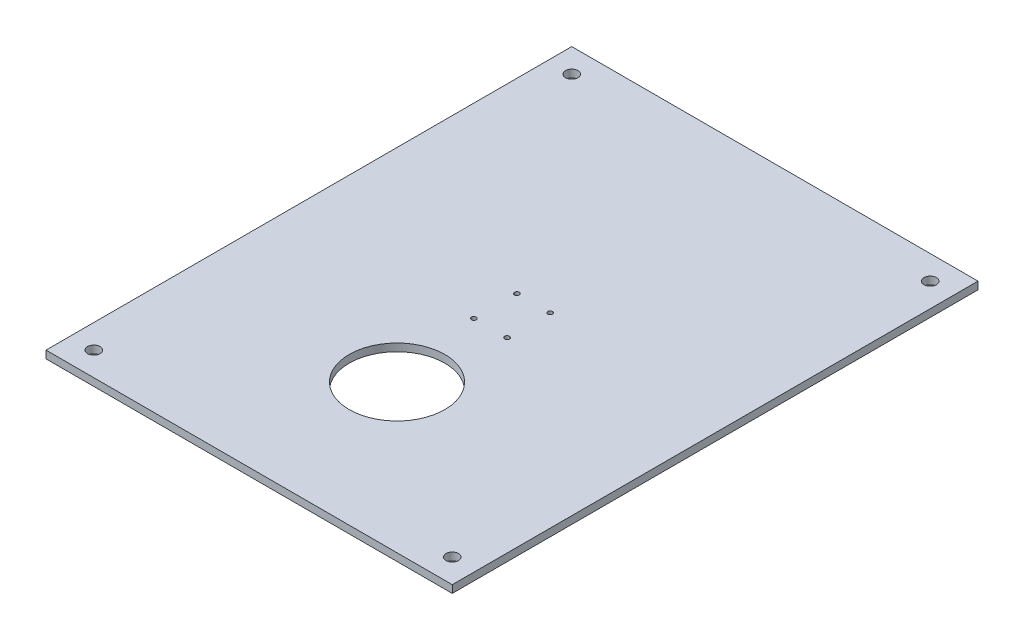
from build123d import *

# Parameters (mm, degrees)
SKETCH2_W           = 170
SKETCH2_H           = 220
SKETCH2_R           = 2.6
SKETCH2_R_2         = 1
SKETCH2_R_3         = 20
BOSS_EXTRUDE1_DEPTH = 3.175


with BuildPart() as part:
    # Sketch2 → Boss-Extrude1 (new body)
    with BuildSketch(Plane(origin=(0, 0, 0), x_dir=(1, 0, 0), z_dir=(0, 1, 0))):
        Rectangle(SKETCH2_W, SKETCH2_H)
        with Locations((-75, 100)):
            Circle(SKETCH2_R, mode=Mode.SUBTRACT)
        with Locations((75, 100)):
            Circle(SKETCH2_R, mode=Mode.SUBTRACT)
        with Locations((75, -100)):
            Circle(SKETCH2_R, mode=Mode.SUBTRACT)
        with Locations((-75, -100)):
            Circle(SKETCH2_R, mode=Mode.SUBTRACT)
        with Locations((-6.954545455, 9)):
            Circle(SKETCH2_R_2, mode=Mode.SUBTRACT)
        with Locations((6.954545455, 9)):
            Circle(SKETCH2_R_2, mode=Mode.SUBTRACT)
        with Locations((6.954545455, -9)):
            Circle(SKETCH2_R_2, mode=Mode.SUBTRACT)
        with Locations((-6.954545455, -9)):
            Circle(SKETCH2_R_2, mode=Mode.SUBTRACT)
        with Locations((0, -48.117139718)):
            Circle(SKETCH2_R_3, mode=Mode.SUBTRACT)
    extrude(amount=BOSS_EXTRUDE1_DEPTH)


solid = part.part
